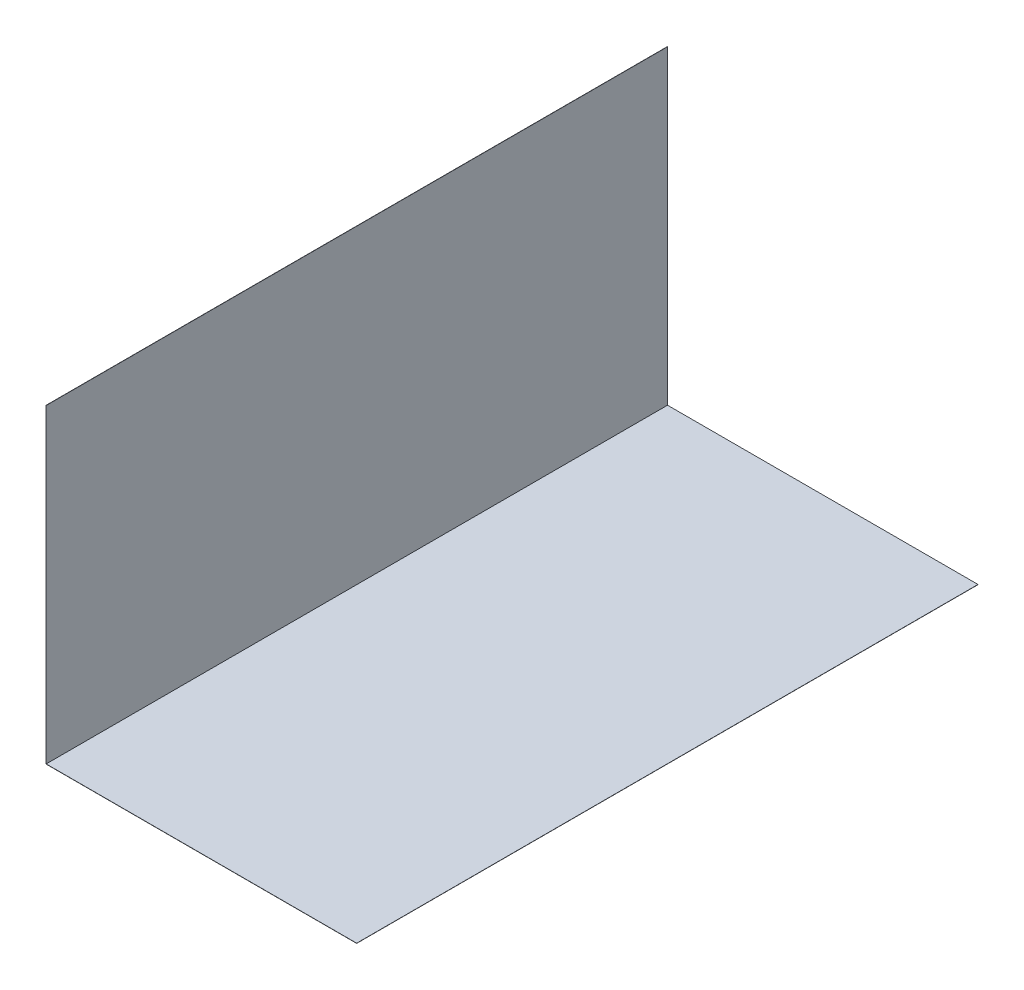
from build123d import *

# Parameters (mm, degrees)
BOSS_EXTRUDE1_DEPTH = 30480


with BuildPart() as part:
    # Sketch1 → Boss-Extrude1 (new body)
    with BuildSketch(Plane.XY):
        Polygon((-7610, 7620), (-7610, -7610), (7620, -7610), (7620, -7620), (-7620, -7620), (-7620, 7620), align=None)
    extrude(amount=BOSS_EXTRUDE1_DEPTH)


solid = part.part
